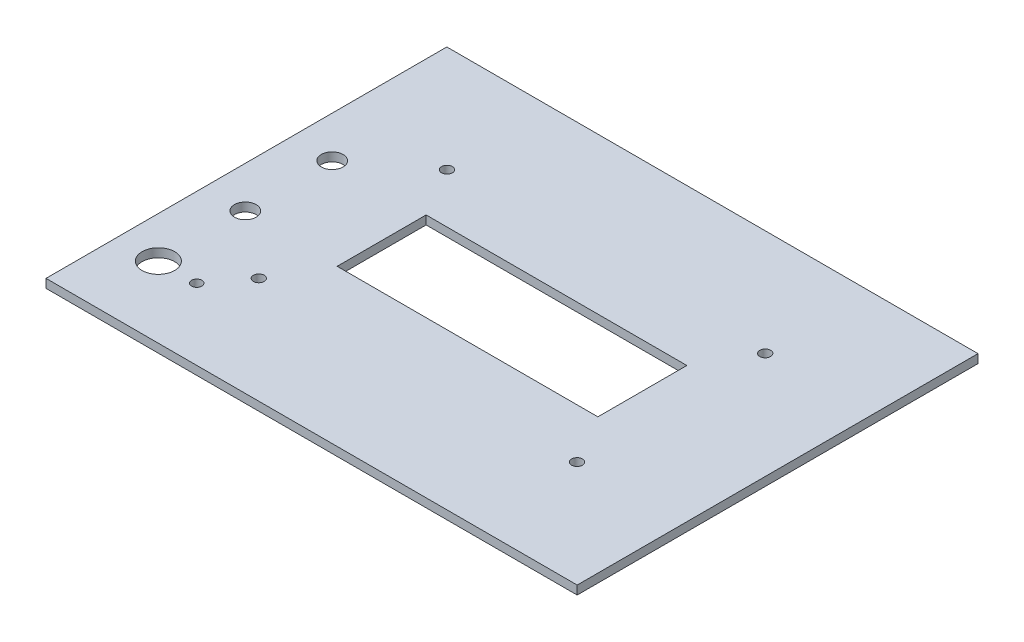
from build123d import *

# Parameters (mm, degrees)
SKETCH1_W           = 155.2448
SKETCH1_H           = 117.1448
BOSS_EXTRUDE1_DEPTH = 2.54
SKETCH2_R           = 1.5875
SKETCH2_R_2         = 3.175
SKETCH2_R_3         = 4.7625
SKETCH2_R_4         = 1.5
SKETCH2_W           = 76.2
SKETCH2_H           = 26
CUT_EXTRUDE1_DEPTH  = 2.54


with BuildPart() as part:
    # Sketch1 → Boss-Extrude1 (new body)
    with BuildSketch(Plane(origin=(0, 0, 0), x_dir=(1, 0, 0), z_dir=(0, 1, 0))):
        with Locations((77.6224, 58.5724)):
            Rectangle(SKETCH1_W, SKETCH1_H)
    extrude(amount=BOSS_EXTRUDE1_DEPTH)

    # Sketch2 → Cut-Extrude1 (cut)
    with BuildSketch(Plane(origin=(0, 2.54, 0), x_dir=(1, 0, 0), z_dir=(0, 1, 0))):
        with Locations((31.097, 86.0978)):
            Circle(SKETCH2_R)
        with Locations((31.097, 31.0978)):
            Circle(SKETCH2_R)
        with Locations((124.097, 86.0978)):
            Circle(SKETCH2_R)
        with Locations((124.097, 31.0978)):
            Circle(SKETCH2_R)
        with Locations((12.047, 71.5978)):
            Circle(SKETCH2_R_2)
        with Locations((12.047, 46.1978)):
            Circle(SKETCH2_R_2)
        with Locations((12.047, 20.7978)):
            Circle(SKETCH2_R_3)
        with Locations((23.247, 20.7978)):
            Circle(SKETCH2_R_4)
        with Locations((77.597, 58.5978)):
            Rectangle(SKETCH2_W, SKETCH2_H)
    extrude(amount=-CUT_EXTRUDE1_DEPTH, mode=Mode.SUBTRACT)


solid = part.part
